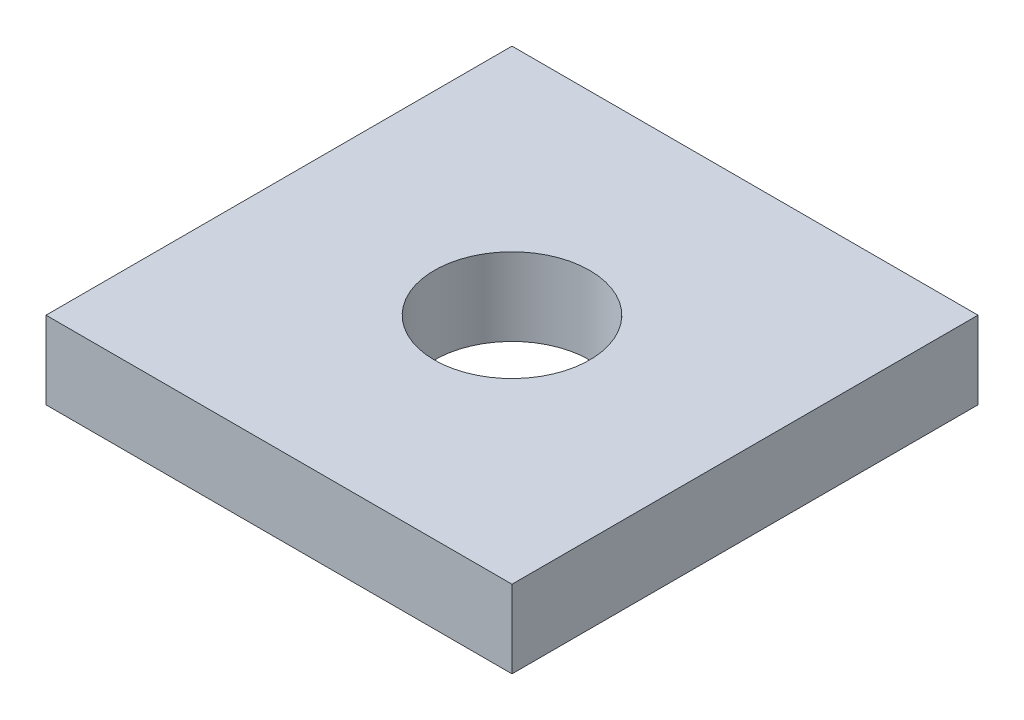
from build123d import *

# Parameters (mm, degrees)
SKETCH1_W           = 76.2
SKETCH1_H           = 76.2
BOSS_EXTRUDE1_DEPTH = 12.7
CUT_EXTRUDE1_REACH  = 14.7
SKETCH2_R           = 12.7


with BuildPart() as part:
    # Sketch1 → Boss-Extrude1 (new body)
    with BuildSketch(Plane(origin=(0, 0, 0), x_dir=(1, 0, 0), z_dir=(0, 1, 0))):
        with Locations((38.1, 38.1)):
            Rectangle(SKETCH1_W, SKETCH1_H)
    extrude(amount=BOSS_EXTRUDE1_DEPTH)

    # Sketch2 → Cut-Extrude1 (cut, up to next)
    with BuildSketch(Plane(origin=(0, 12.7, 0), x_dir=(-1, 0, 0), z_dir=(0, 1, 0)), mode=Mode.PRIVATE) as cut_extrude1_sk1:
        with Locations((-38.1, -38.1)):
            Circle(SKETCH2_R)
    cut_extrude1_tool1 = extrude(cut_extrude1_sk1.sketch, amount=-CUT_EXTRUDE1_REACH, mode=Mode.PRIVATE) & part.part
    add(cut_extrude1_tool1.solids().sort_by_distance((38.1, 12.7, -38.1))[0], mode=Mode.SUBTRACT)


solid = part.part
